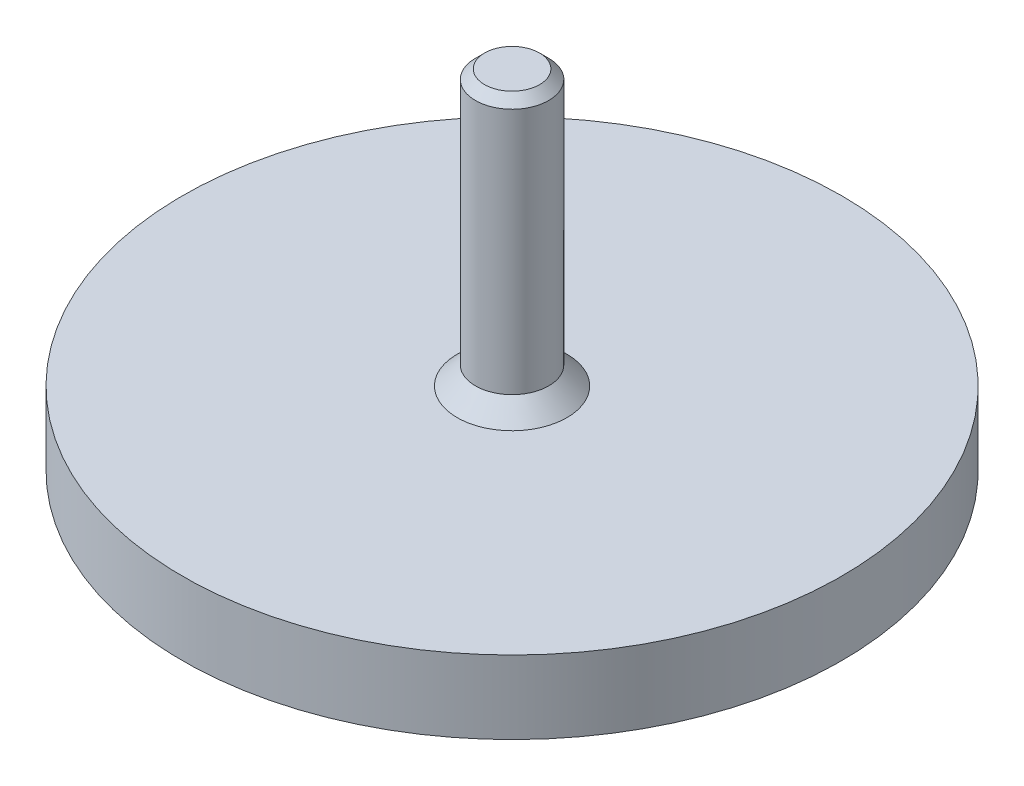
from build123d import *

# Parameters (mm, degrees)
CHANFREIN1_SIZE = 1
CHANFREIN2_SIZE = 0.5


with BuildPart() as part:
    # Esquisse1 → Révolution1 (revolve)
    with BuildSketch(Plane.XY):
        Polygon((0, 0), (-18, 0), (-18, 4), (-2, 4), (-2, 19), (0, 19), align=None)
    revolve(axis=Axis((0, 0, 0), (0, 1, 0)))

    # Chanfrein1
    chanfrein1_edges = [part.edges().sort_by_distance(p)[0] for p in [
        (2, 4, 0),
    ]]
    chamfer(chanfrein1_edges, length=CHANFREIN1_SIZE)

    # Chanfrein2
    chanfrein2_edges = [part.edges().sort_by_distance(p)[0] for p in [
        (2, 19, 0),
    ]]
    chamfer(chanfrein2_edges, length=CHANFREIN2_SIZE)


solid = part.part
